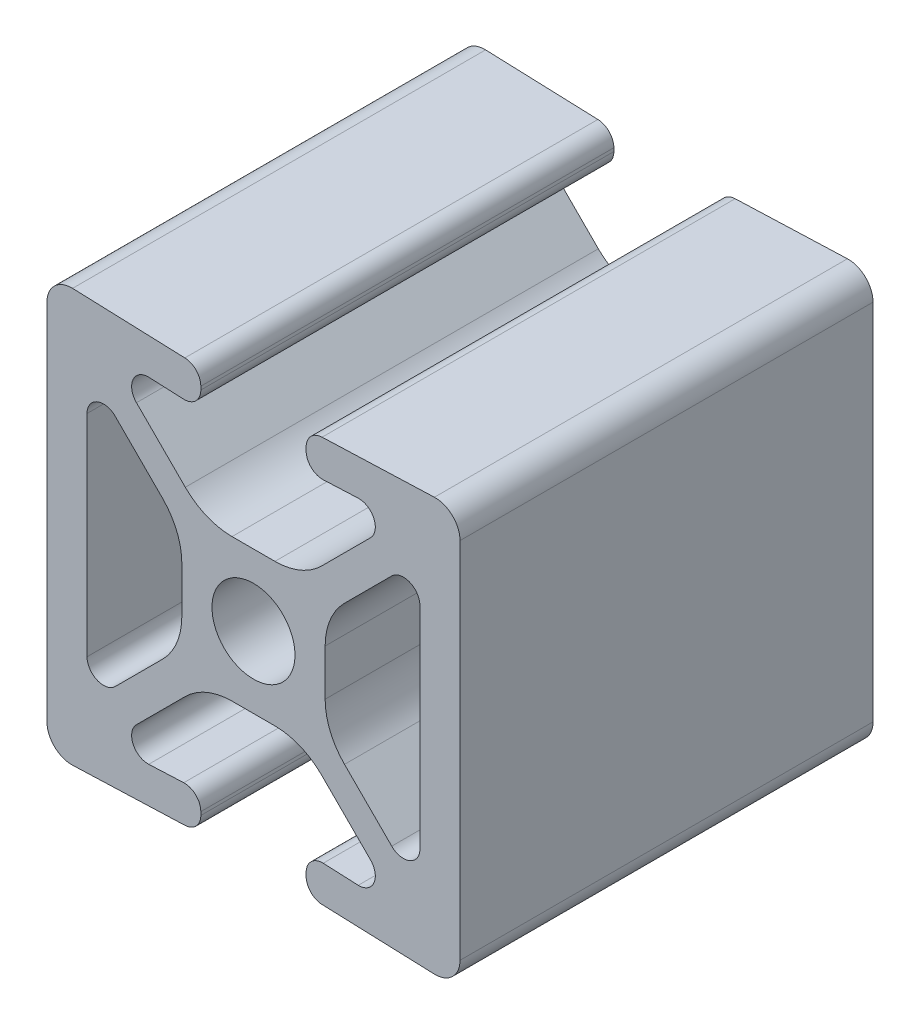
from build123d import *

# Parameters (mm, degrees)
EXTRUDE1_DEPTH = 25.4


with BuildPart() as part:
    # Sketch1 → Extrude1 (new body)
    with BuildSketch(Plane.XY):
        with BuildLine():
            Line((11.125675541, 12.699168884), (4.22095036, 12.445641481))
            ThreePointArc((4.22095036, 12.445641481), (3.524314259, 12.136654887), (3.2385, 11.430195559))
            Line((3.2385, 11.430195559), (3.2385, 11.226884683))
            ThreePointArc((3.2385, 11.226884683), (3.548040671, 10.496698941), (4.28804964, 10.21143876))
            Line((4.28804964, 10.21143876), (6.44345036, 10.308051727))
            ThreePointArc((6.44345036, 10.308051727), (7.4091133, 9.696859185), (7.19542049, 8.574185315))
            Line((7.19542049, 8.574185315), (4.193053216, 5.571818041))
            ThreePointArc((4.193053216, 5.571818041), (2.874596726, 4.69085358), (1.319371257, 4.3815))
            Line((1.319371257, 4.3815), (-1.319371257, 4.3815))
            ThreePointArc((-1.319371257, 4.3815), (-2.874596726, 4.69085358), (-4.193053216, 5.571818041))
            Line((-4.193053216, 5.571818041), (-7.19542049, 8.574185315))
            ThreePointArc((-7.19542049, 8.574185315), (-7.4091133, 9.696859185), (-6.44345036, 10.308051727))
            Line((-6.44345036, 10.308051727), (-4.28804964, 10.21143876))
            ThreePointArc((-4.28804964, 10.21143876), (-3.548040671, 10.496698941), (-3.2385, 11.226884683))
            Line((-3.2385, 11.226884683), (-3.2385, 11.430195559))
            ThreePointArc((-3.2385, 11.430195559), (-3.524314259, 12.136654887), (-4.22095036, 12.445641481))
            Line((-4.22095036, 12.445641481), (-11.125675541, 12.699168884))
            ThreePointArc((-11.125675541, 12.699168884), (-12.235688993, 12.271278612), (-12.7, 11.176))
            Line((-12.7, 11.176), (-12.7, 0))
            Line((-12.7, 0), (-12.7, -11.176))
            ThreePointArc((-12.7, -11.176), (-12.235688993, -12.271278612), (-11.125675541, -12.699168884))
            Line((-11.125675541, -12.699168884), (-4.22095036, -12.445641481))
            ThreePointArc((-4.22095036, -12.445641481), (-3.524314259, -12.136654887), (-3.2385, -11.430195559))
            Line((-3.2385, -11.430195559), (-3.2385, -11.226884683))
            ThreePointArc((-3.2385, -11.226884683), (-3.548040671, -10.496698941), (-4.28804964, -10.21143876))
            Line((-4.28804964, -10.21143876), (-6.44345036, -10.308051727))
            ThreePointArc((-6.44345036, -10.308051727), (-7.4091133, -9.696859185), (-7.19542049, -8.574185315))
            Line((-7.19542049, -8.574185315), (-4.193053216, -5.571818041))
            ThreePointArc((-4.193053216, -5.571818041), (-2.874596726, -4.69085358), (-1.319371257, -4.3815))
            Line((-1.319371257, -4.3815), (1.319371257, -4.3815))
            ThreePointArc((1.319371257, -4.3815), (2.874596726, -4.69085358), (4.193053216, -5.571818041))
            Line((4.193053216, -5.571818041), (7.19542049, -8.574185315))
            ThreePointArc((7.19542049, -8.574185315), (7.4091133, -9.696859185), (6.44345036, -10.308051727))
            Line((6.44345036, -10.308051727), (4.28804964, -10.21143876))
            ThreePointArc((4.28804964, -10.21143876), (3.548040671, -10.496698941), (3.2385, -11.226884683))
            Line((3.2385, -11.226884683), (3.2385, -11.430195559))
            ThreePointArc((3.2385, -11.430195559), (3.524314259, -12.136654887), (4.22095036, -12.445641481))
            Line((4.22095036, -12.445641481), (11.125675541, -12.699168884))
            ThreePointArc((11.125675541, -12.699168884), (12.235688993, -12.271278612), (12.7, -11.176))
            Line((12.7, -11.176), (12.7, 0))
            Line((12.7, 0), (12.7, 11.176))
            ThreePointArc((12.7, 11.176), (12.235688993, 12.271278612), (11.125675541, 12.699168884))
        make_face()
        with BuildLine():
            Line((-8.50177951, 7.19542049), (-5.597218041, 4.290859021))
            ThreePointArc((-5.597218041, 4.290859021), (-4.71625358, 2.972402531), (-4.4069, 1.417177062))
            Line((-4.4069, 1.417177062), (-4.4069, -1.417177062))
            ThreePointArc((-4.4069, -1.417177062), (-4.71625358, -2.972402531), (-5.597218041, -4.290859021))
            Line((-5.597218041, -4.290859021), (-8.50177951, -7.19542049))
            ThreePointArc((-8.50177951, -7.19542049), (-9.609006367, -7.415661605), (-10.2362, -6.477))
            Line((-10.2362, -6.477), (-10.2362, 0))
            Line((-10.2362, 0), (-10.2362, 6.477))
            ThreePointArc((-10.2362, 6.477), (-9.609006367, 7.415661605), (-8.50177951, 7.19542049))
        make_face(mode=Mode.SUBTRACT)
        with BuildLine():
            Line((10.2362, 0), (10.2362, 6.477))
            ThreePointArc((10.2362, 6.477), (9.609006367, 7.415661605), (8.50177951, 7.19542049))
            Line((8.50177951, 7.19542049), (5.597218041, 4.290859021))
            ThreePointArc((5.597218041, 4.290859021), (4.71625358, 2.972402531), (4.4069, 1.417177062))
            Line((4.4069, 1.417177062), (4.4069, -1.417177062))
            ThreePointArc((4.4069, -1.417177062), (4.71625358, -2.972402531), (5.597218041, -4.290859021))
            Line((5.597218041, -4.290859021), (8.50177951, -7.19542049))
            ThreePointArc((8.50177951, -7.19542049), (9.609006367, -7.415661605), (10.2362, -6.477))
            Line((10.2362, -6.477), (10.2362, 0))
        make_face(mode=Mode.SUBTRACT)
        with BuildLine():
            ThreePointArc((0, 2.5527), (-1.80503148, 1.80503148), (-2.5527, 0))
            ThreePointArc((-2.5527, 0), (-1.80503148, -1.80503148), (0, -2.5527))
            ThreePointArc((0, -2.5527), (1.80503148, -1.80503148), (2.5527, 0))
            ThreePointArc((2.5527, 0), (1.80503148, 1.80503148), (0, 2.5527))
        make_face(mode=Mode.SUBTRACT)
    extrude(amount=EXTRUDE1_DEPTH)


solid = part.part
